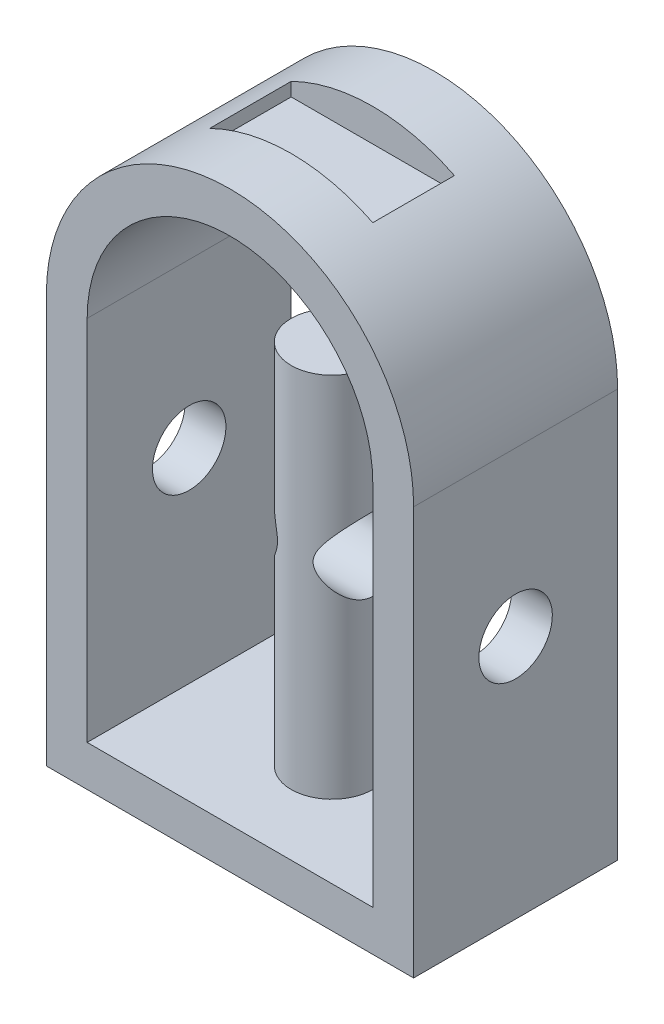
from build123d import *

# Parameters (mm, degrees)
BOSS_EXTRUDE1_DEPTH     = 50
SKETCH3_W               = 40
SKETCH3_H               = 20
CUT_EXTRUDE1_DEPTH      = 8
BOSS_EXTRUDE2_REACH     = 102
SKETCH4_R               = 10
SKETCH6_R               = 9
CUT_EXTRUDE2_DEPTH      = 141
CUT_EXTRUDE2_DEPTH_BACK = 1


with BuildPart() as part:
    # Sketch1 → Boss-Extrude1 (new body)
    with BuildSketch(Plane.XY):
        with BuildLine():
            Line((80, 90), (80, -10))
            Line((80, -10), (-10, -10))
            Line((-10, -10), (-10, 90))
            ThreePointArc((-10, 90), (35, 135), (80, 90))
        make_face()
        with BuildLine():
            Line((0, 90), (0, 0))
            Line((0, 0), (70, 0))
            Line((70, 0), (70, 90))
            ThreePointArc((70, 90), (35, 125), (0, 90))
        make_face(mode=Mode.SUBTRACT)
    extrude(amount=BOSS_EXTRUDE1_DEPTH)

    # Sketch3 → Cut-Extrude1 (cut)
    with BuildSketch(Plane(origin=(0, 135, 0), x_dir=(1, 0, 0), z_dir=(0, 1, 0))):
        with Locations((35, -25)):
            Rectangle(SKETCH3_W, SKETCH3_H)
    extrude(amount=-CUT_EXTRUDE1_DEPTH, mode=Mode.SUBTRACT)

    # Sketch4 → Boss-Extrude2 (add, up to next)
    with BuildSketch(Plane(origin=(0, 90, 0), x_dir=(1, 0, 0), z_dir=(0, 1, 0)), mode=Mode.PRIVATE) as boss_extrude2_sk1:
        with Locations((35, -25)):
            Circle(SKETCH4_R)
    boss_extrude2_tool1 = extrude(boss_extrude2_sk1.sketch, amount=-BOSS_EXTRUDE2_REACH, mode=Mode.PRIVATE) - part.part
    add(boss_extrude2_tool1.solids().sort_by_distance((35, 90, 25))[0])

    # Sketch6 → Cut-Extrude2 (cut, two sides)
    with BuildSketch(Plane.ZY.offset(-130)) as cut_extrude2_sk:
        with Locations((25, 50)):
            Circle(SKETCH6_R)
    extrude(amount=CUT_EXTRUDE2_DEPTH, mode=Mode.SUBTRACT)
    extrude(cut_extrude2_sk.sketch, amount=-CUT_EXTRUDE2_DEPTH_BACK, mode=Mode.SUBTRACT)


solid = part.part
